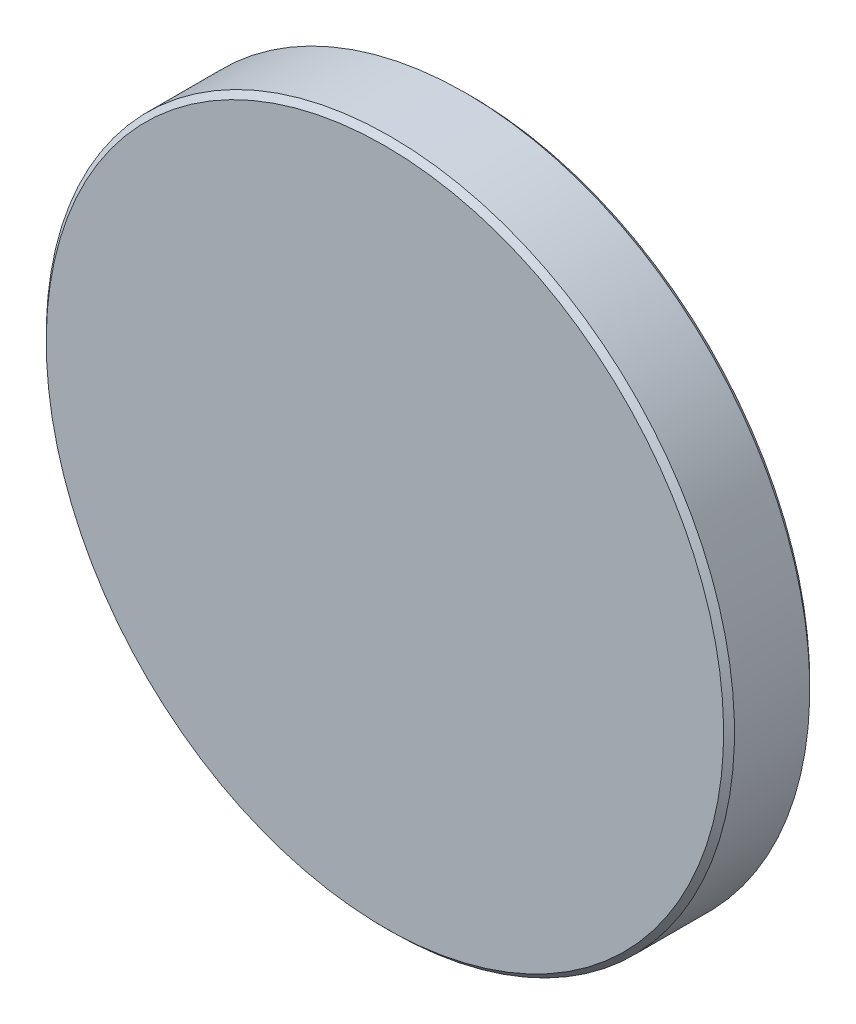
from build123d import *

# Parameters (mm, degrees)
CHAMFER1_SIZE       = 1
SKETCH2_R           = 54
BOSS_EXTRUDE1_DEPTH = 15.858462


with BuildPart() as part:
    # Sketch1 → Revolve3 (revolve)
    with BuildSketch(Plane(origin=(0, 0, 0), x_dir=(0, 0, -1), z_dir=(1, 0, 0))):
        with BuildLine():
            Line((-458.414283312, 54), (-458.414283312, 63.3349))
            Line((-458.414283312, 63.3349), (-442.555821638, 63.3349))
            Line((-442.555821638, 63.3349), (-442.555821638, 54))
            ThreePointArc((-442.555821638, 54), (-443.54515622, 27.008055426), (-443.875, 0))
            Line((-443.875, 0), (-451.375, 0))
            ThreePointArc((-451.375, 0), (-453.142234121, 27.228438761), (-458.414283312, 54))
        make_face()
    revolve(axis=Axis((0, 0, 662.018), (0, 0, -1)))

    # Chamfer1
    chamfer1_edges = [part.edges().sort_by_distance(p)[0] for p in [
        (0, -63.3349, 442.555821638),
        (0, -63.3349, 458.414283312),
    ]]
    chamfer(chamfer1_edges, length=CHAMFER1_SIZE)

    # Sketch2 → Boss-Extrude1 (add)
    with BuildSketch(Plane.XY.offset(458.414283312)):
        Circle(SKETCH2_R)
    extrude(amount=-BOSS_EXTRUDE1_DEPTH)


solid = part.part
